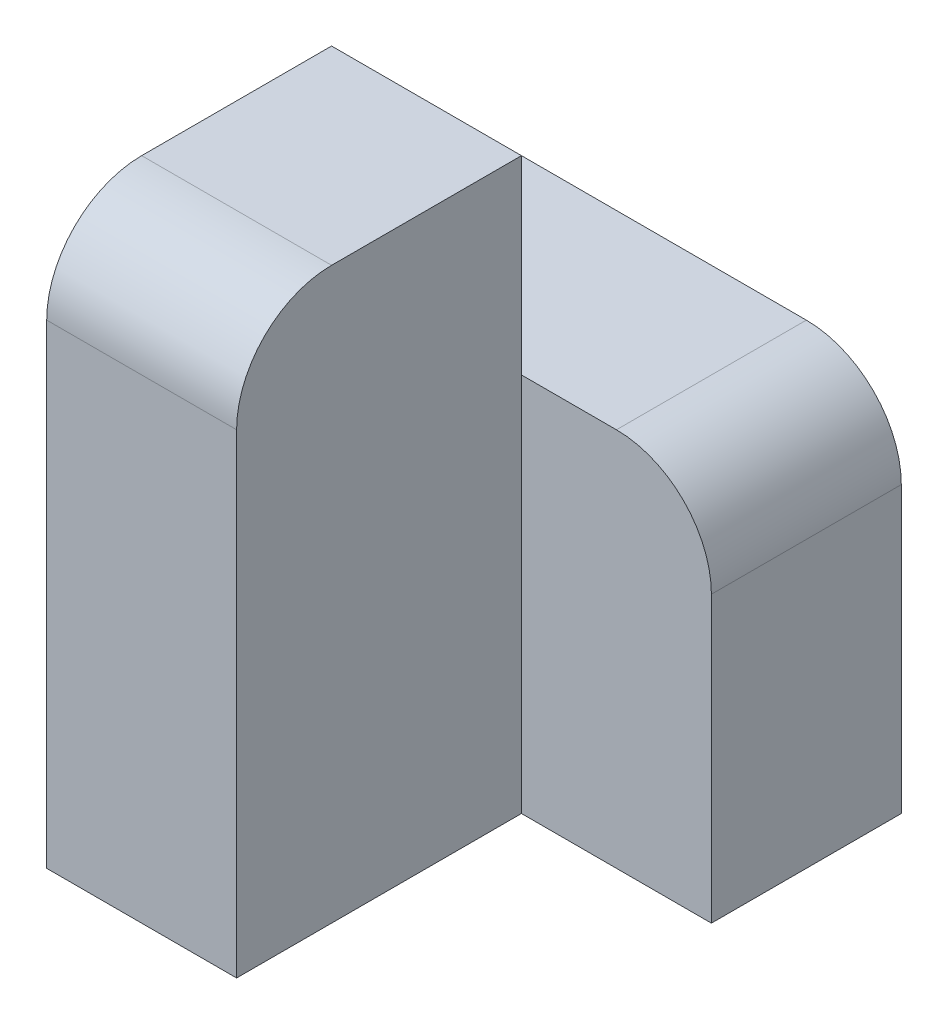
from build123d import *

# Parameters (mm, degrees)
SKETCH1_W           = 20
SKETCH1_H           = 60
BOSS_EXTRUDE1_DEPTH = 30
SKETCH2_W           = 40
SKETCH2_H           = 40
BOSS_EXTRUDE2_DEPTH = 20
FILLET1_R           = 10


with BuildPart() as part:
    # Sketch1 → Boss-Extrude1 (new body)
    with BuildSketch(Plane.XY):
        with Locations((-20, -30)):
            Rectangle(SKETCH1_W, SKETCH1_H)
    extrude(amount=BOSS_EXTRUDE1_DEPTH)

    # Sketch2 → Boss-Extrude2 (add)
    with BuildSketch(Plane.XY):
        with Locations((-10, -40)):
            Rectangle(SKETCH2_W, SKETCH2_H)
    extrude(amount=-BOSS_EXTRUDE2_DEPTH)

    # Fillet1
    fillet1_edges = [part.edges().sort_by_distance(p)[0] for p in [
        (10, -20, -10),
        (-20, 0, 30),
    ]]
    fillet(fillet1_edges, radius=FILLET1_R)


solid = part.part
